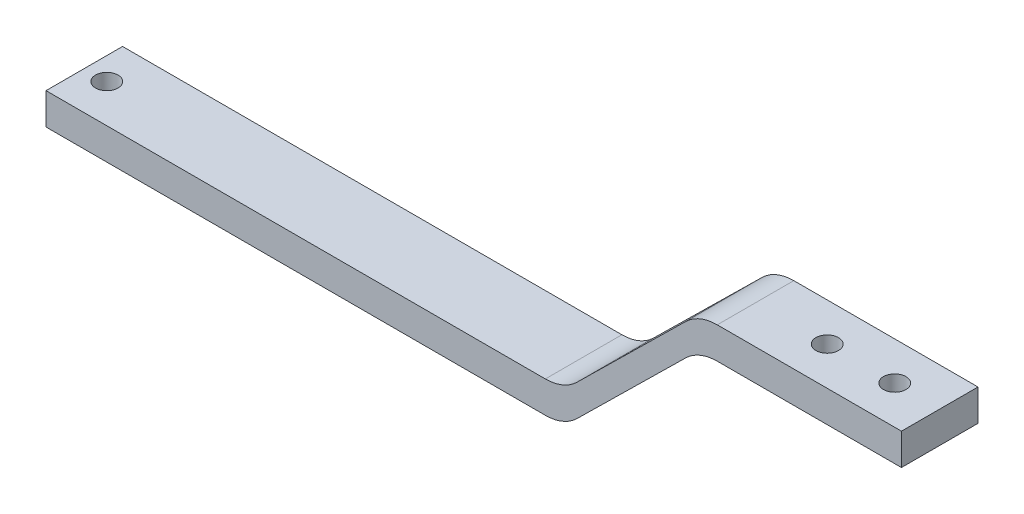
from build123d import *

# Parameters (mm, degrees)
EXTRUDE1_DEPTH = 17
FILLET1_R      = 10
SKETCH2_R      = 2.5
EXTRUDE2_DEPTH = 17
SKETCH3_R      = 2.5
EXTRUDE3_DEPTH = 17


with BuildPart() as part:
    # Sketch1 → Extrude1 (new body)
    with BuildSketch(Plane.XY):
        Polygon((-135.932508131, 32.133218497), (-20.932508131, 32.133218497), (9.067491869, 61.633218497), (54.067491869, 61.633218497), (54.067491869, 54.633218497), (9.067491869, 54.633218497), (-20.932508131, 25.133218497), (-135.932508131, 25.133218497), align=None)
    extrude(amount=EXTRUDE1_DEPTH)

    # Fillet1
    fillet1_edges = [part.edges().sort_by_distance(p)[0] for p in [
        (-20.932508131, 32.133218497, 8.5),
        (9.067491869, 61.633218497, 8.5),
        (9.067491869, 54.633218497, 8.5),
        (-20.932508131, 25.133218497, 8.5),
    ]]
    fillet(fillet1_edges, radius=FILLET1_R)

    # Sketch2 → Extrude2 (cut)
    with BuildSketch(Plane.XZ.offset(-54.633218497)):
        with Locations((44.067491869, 8.5)):
            Circle(SKETCH2_R)
        with Locations((29.067491869, 8.5)):
            Circle(SKETCH2_R)
    extrude(amount=-EXTRUDE2_DEPTH, mode=Mode.SUBTRACT)

    # Sketch3 → Extrude3 (cut)
    with BuildSketch(Plane.XZ.offset(-25.133218497)):
        with Locations((-130.932508131, 8.5)):
            Circle(SKETCH3_R)
    extrude(amount=-EXTRUDE3_DEPTH, mode=Mode.SUBTRACT)


solid = part.part
